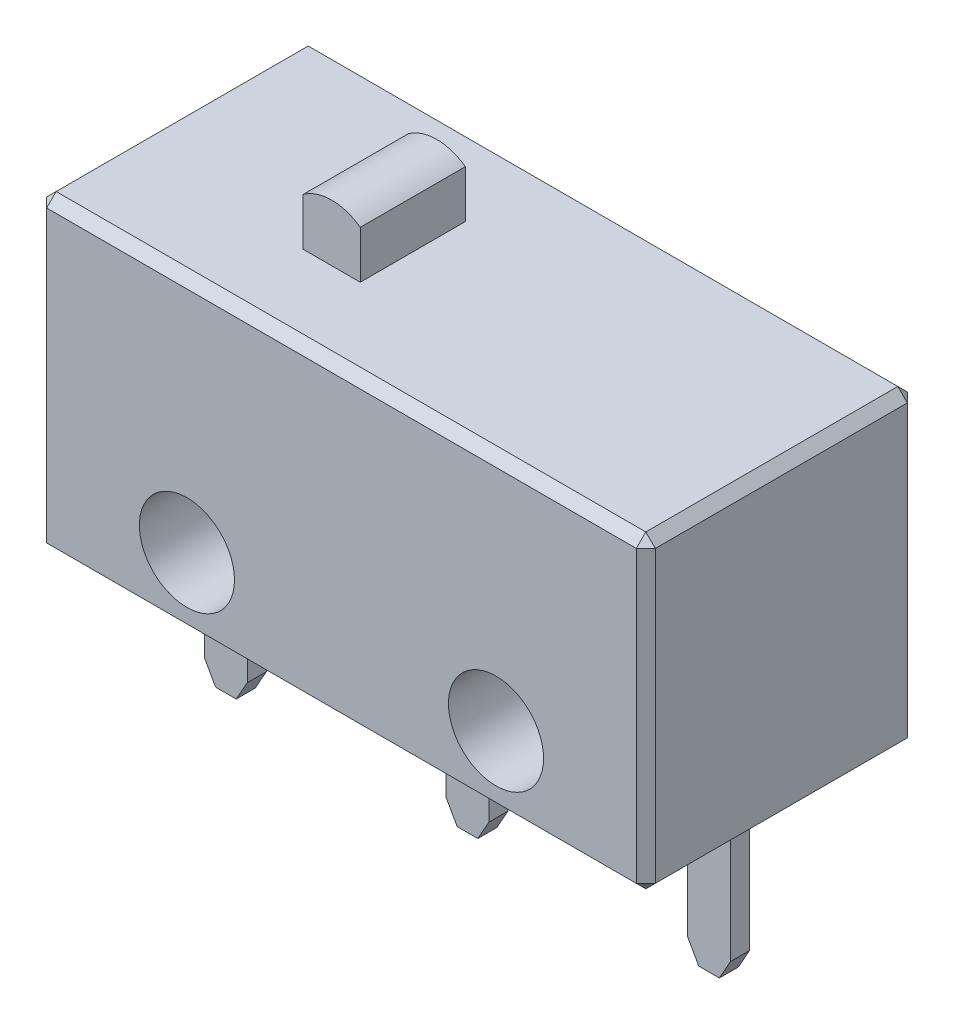
from build123d import *

# Parameters (mm, degrees)
SKETCH2_W           = 12.8
SKETCH2_H           = 6.5
SKETCH2_R           = 1
EXTRUDE1_DEPTH      = 2.85
EXTRUDE2_DEPTH      = 1.1049
BOSS_EXTRUDE2_DEPTH = 0.2
CHAMFER1_SIZE       = 0.2


with BuildPart() as part:
    # Sketch2 → Extrude1 (new body, symmetric)
    with BuildSketch(Plane.XY):
        with Locations((0, 3.25)):
            Rectangle(SKETCH2_W, SKETCH2_H)
        with Locations((3.25, 1.5)):
            Circle(SKETCH2_R, mode=Mode.SUBTRACT)
        with Locations((-3.25, 1.5)):
            Circle(SKETCH2_R, mode=Mode.SUBTRACT)
    extrude(amount=EXTRUDE1_DEPTH, both=True)

    # Sketch12 → Boss-Extrude2 (add, symmetric)
    with BuildSketch(Plane.XY):
        Polygon((-0.45, 0), (-0.45, -2.884856908), (-0.217069054, -3.3), (0.217069054, -3.3), (0.45, -2.884856908), (0.45, 0), align=None)
        Polygon((-5.53, -2.884856908), (-5.297069054, -3.3), (-4.862930946, -3.3), (-4.63, -2.884856908), (-4.63, 0), (-5.53, 0), align=None)
        Polygon((4.63, -2.884856908), (4.862930946, -3.3), (5.297069054, -3.3), (5.53, -2.884856908), (5.53, 0), (4.63, 0), align=None)
    extrude(amount=BOSS_EXTRUDE2_DEPTH, both=True)

    # Chamfer1
    chamfer1_edges = [part.edges().sort_by_distance(p)[0] for p in [
        (-6.4, 3.25, 2.85),
        (0, 0, 2.85),
        (6.4, 3.25, 2.85),
        (0, 0, -2.85),
        (-6.4, 3.25, -2.85),
        (0, 6.5, -2.85),
        (6.4, 3.25, -2.85),
        (0, 6.5, 2.85),
        (6.4, 0, 0),
        (-6.4, 0, 0),
        (-6.4, 6.5, 0),
        (6.4, 6.5, 0),
    ]]
    chamfer(chamfer1_edges, length=CHAMFER1_SIZE)


with BuildPart() as body_2:
    # Sketch3 → Extrude2 (new body, symmetric)
    with BuildSketch(Plane.XY):
        with BuildLine():
            Line((-2.55, 6.5), (-2.55, 7.5))
            ThreePointArc((-2.55, 7.5), (-1.95, 7.69608781), (-1.35, 7.5))
            Line((-1.35, 7.5), (-1.35, 6.5))
            Line((-1.35, 6.5), (-2.55, 6.5))
        make_face()
    extrude(amount=EXTRUDE2_DEPTH, both=True)


solid = Compound([part.part, body_2.part])
